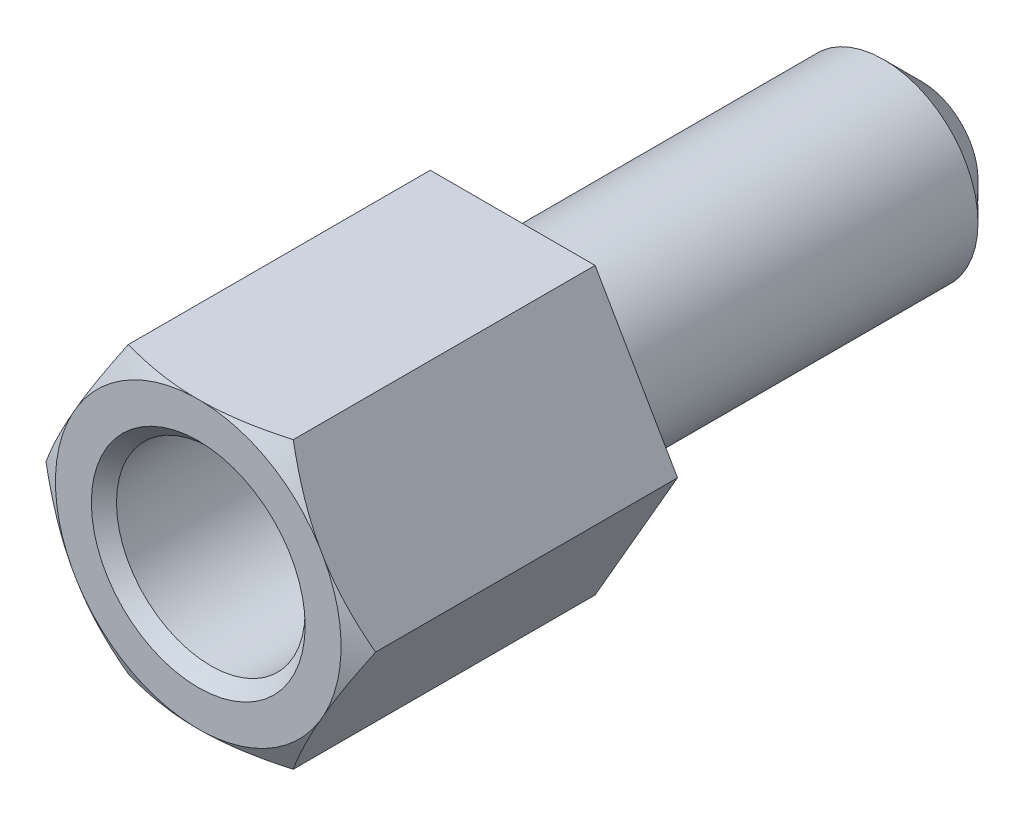
from build123d import *

# Parameters (mm, degrees)
BOSS_EXTRUDE1_DEPTH     = 5
SKETCH2_R               = 1.5
CUT_EXTRUDE1_DEPTH      = 1
CUT_EXTRUDE1_DEPTH_BACK = 4
CHAMFER1_SIZE           = 0.2
SKETCH4_R               = 1.5
BOSS_EXTRUDE2_DEPTH     = 6.5
CHAMFER2_SIZE           = 0.6


with BuildPart() as part:
    # Sketch1 → Boss-Extrude1 (new body)
    with BuildSketch(Plane.XY):
        Polygon((2.621170222, 0), (1.310585111, 2.27), (-1.310585111, 2.27), (-2.621170222, 0), (-1.310585111, -2.27), (1.310585111, -2.27), align=None)
    extrude(amount=BOSS_EXTRUDE1_DEPTH)

    # Sketch2 → Cut-Extrude1 (cut, two sides)
    with BuildSketch(Plane.XY.offset(5)) as cut_extrude1_sk:
        Circle(SKETCH2_R)
    extrude(amount=CUT_EXTRUDE1_DEPTH, mode=Mode.SUBTRACT)
    extrude(cut_extrude1_sk.sketch, amount=-CUT_EXTRUDE1_DEPTH_BACK, mode=Mode.SUBTRACT)

    # Sketch3 → Cut-Revolve1 (revolve, cut)
    with BuildSketch(Plane(origin=(0, 0, 0), x_dir=(1, 0, 0), z_dir=(0, 1, 0))):
        Polygon((-2.621170222, -5), (-2.271170222, -5), (-2.621170222, -4.8), align=None)
    revolve(axis=Axis((0, 0, 1), (0, 0, 1)), mode=Mode.SUBTRACT)

    # Chamfer1
    chamfer1_edges = [part.edges().sort_by_distance(p)[0] for p in [
        (-1.5, 0, 5),
    ]]
    chamfer(chamfer1_edges, length=CHAMFER1_SIZE)

    # Sketch4 → Boss-Extrude2 (add)
    with BuildSketch(Plane(origin=(0, 0, 0), x_dir=(-1, 0, 0), z_dir=(0, 0, -1))):
        Circle(SKETCH4_R)
    extrude(amount=BOSS_EXTRUDE2_DEPTH)

    # Chamfer2
    chamfer2_edges = [part.edges().sort_by_distance(p)[0] for p in [
        (1.5, 0, -6.5),
    ]]
    chamfer(chamfer2_edges, length=CHAMFER2_SIZE)


solid = part.part
